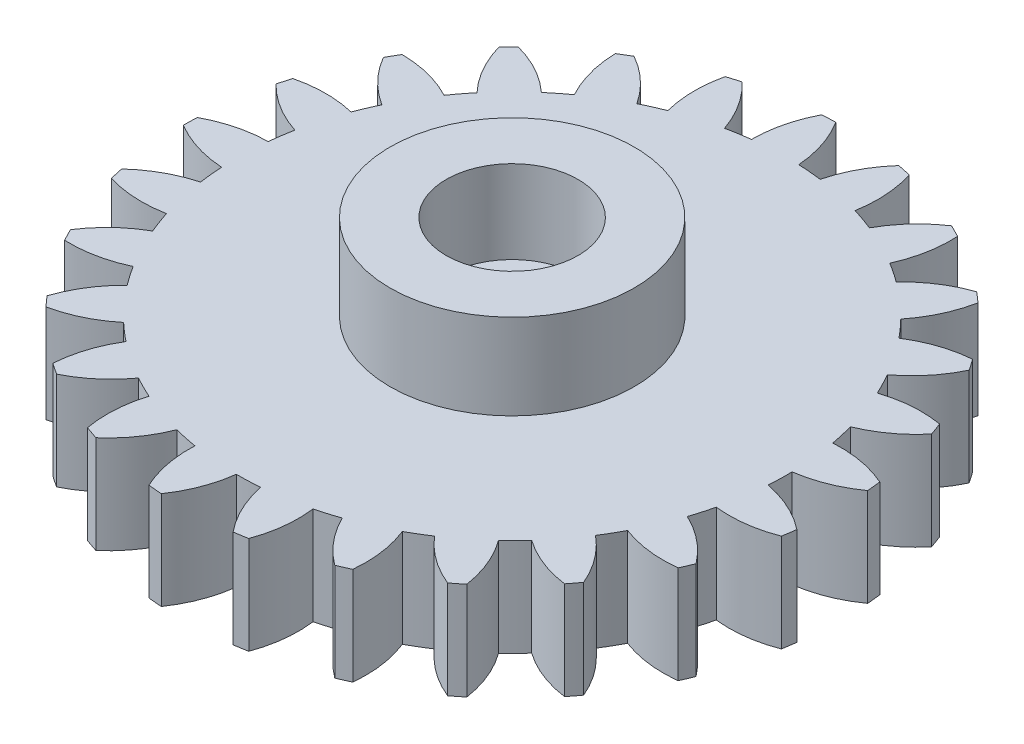
from build123d import *

# Parameters (mm, degrees)
BOSS_EXTRUDE1_DEPTH = 4
SKETCH2_R           = 5
BOSS_EXTRUDE2_DEPTH = 3.5
SKETCH3_R           = 2.7
CUT_EXTRUDE1_DEPTH  = 3.4
SKETCH4_R           = 2.35
CUT_EXTRUDE2_DEPTH  = 1.5


with BuildPart() as part:
    # Sketch1 → Boss-Extrude1 (new body)
    with BuildSketch(Plane(origin=(0, 0, 0), x_dir=(1, 0, 0), z_dir=(0, 1, 0))):
        with BuildLine():
            ThreePointArc((3.901208796, 14.038686533), (3.966253303, 15.234612101), (3.74502345, 16.41169583))
            ThreePointArc((3.74502345, 16.41169583), (3.4723799, 16.473432267), (3.198516489, 16.529510113))
            ThreePointArc((3.198516489, 16.529510113), (2.511969944, 15.548122017), (2.078508173, 14.431618705))
            ThreePointArc((2.078508173, 14.431618705), (1.601109064, 14.483383768), (1.121935684, 14.514727092))
            ThreePointArc((1.121935684, 14.514727092), (0.887522104, 15.689256371), (0.380513774, 16.774342223))
            ThreePointArc((0.380513774, 16.774342223), (0.101082595, 16.766335403), (-0.178122887, 16.752544399))
            ThreePointArc((-0.178122887, 16.752544399), (-0.599039015, 15.631251232), (-0.741219705, 14.442027366))
            ThreePointArc((-0.741219705, 14.442027366), (-1.216493891, 14.373441804), (-1.688407925, 14.284634846))
            ThreePointArc((-1.688407925, 14.284634846), (-2.207550525, 15.363967841), (-2.968480134, 16.288875881))
            ThreePointArc((-2.968480134, 16.288875881), (-3.237141254, 16.211628901), (-3.504145299, 16.128835588))
            ThreePointArc((-3.504145299, 16.128835588), (-3.632983302, 14.938092323), (-3.474949175, 13.750871212))
            ThreePointArc((-3.474949175, 13.750871212), (-3.918235212, 13.566244507), (-4.353237807, 13.362867335))
            ThreePointArc((-4.353237807, 13.362867335), (-5.124489789, 14.279185585), (-6.091528671, 14.985800439))
            ThreePointArc((-6.091528671, 14.985800439), (-6.332538765, 14.844167012), (-6.570564527, 14.697573597))
            ThreePointArc((-6.570564527, 14.697573597), (-6.399229039, 13.512199013), (-5.95090996, 12.401578126))
            ThreePointArc((-5.95090996, 12.401578126), (-6.334354558, 12.112511054), (-6.7051129, 11.807342604))
            ThreePointArc((-6.7051129, 11.807342604), (-7.680013665, 12.503070462), (-8.792399211, 12.946992921))
            ThreePointArc((-8.792399211, 12.946992921), (-8.990614728, 12.749872395), (-9.184706174, 12.548689882))
            ThreePointArc((-9.184706174, 12.548689882), (-8.723962833, 11.443165424), (-8.013528339, 10.478929154))
            ThreePointArc((-8.013528339, 10.478929154), (-8.313038262, 10.103584863), (-8.596256242, 9.71579999))
            ThreePointArc((-8.596256242, 9.71579999), (-9.713549189, 10.147222317), (-10.901386124, 10.3005591))
            ThreePointArc((-10.901386124, 10.3005591), (-11.044352455, 10.060337283), (-11.182314104, 9.817206709))
            ThreePointArc((-11.182314104, 9.817206709), (-10.46111311, 8.860996544), (-9.533202414, 8.103731404))
            ThreePointArc((-9.533202414, 8.103731404), (-9.729958352, 7.665694155), (-9.907840342, 7.21965881))
            ThreePointArc((-9.907840342, 7.21965881), (-11.097321846, 7.359667754), (-12.285974007, 7.212784147))
            ThreePointArc((-12.285974007, 7.212784147), (-12.364708051, 6.944555059), (-12.437871267, 6.674753212))
            ThreePointArc((-12.437871267, 6.674753212), (-11.50152833, 5.927939542), (-10.414445472, 5.425227285))
            ThreePointArc((-10.414445472, 5.425227285), (-10.496084526, 4.952020569), (-10.557453547, 4.475760793))
            ThreePointArc((-10.557453547, 4.475760793), (-11.744384111, 4.315559077), (-12.85916411, 3.877684317))
            ThreePointArc((-12.85916411, 3.877684317), (-12.868718719, 3.598301779), (-12.872486386, 3.318781301))
            ThreePointArc((-12.872486386, 3.318781301), (-11.779835377, 2.828289175), (-10.601885772, 2.611717061))
            ThreePointArc((-10.601885772, 2.611717061), (-10.563278261, 2.133074197), (-10.504278271, 1.656515143))
            ThreePointArc((-10.504278271, 1.656515143), (-11.614078682, 1.206168831), (-12.584940793, 0.504816199))
            ThreePointArc((-12.584940793, 0.504816199), (-12.524715614, 0.231834843), (-12.458850997, -0.039840966))
            ThreePointArc((-12.458850997, -0.039840966), (-11.278547197, -0.243192124), (-10.08374575, -0.160016072))
            ThreePointArc((-10.08374575, -0.160016072), (-9.927317525, -0.614020193), (-9.751655711, -1.060934567))
            ThreePointArc((-9.751655711, -1.060934567), (-10.714593128, -1.773128561), (-11.480534513, -2.693890499))
            ThreePointArc((-11.480534513, -2.693890499), (-11.354313716, -2.943318251), (-11.222955331, -3.190079))
            ThreePointArc((-11.222955331, -3.190079), (-10.029161569, -3.093511889), (-8.89258205, -2.715813928))
            ThreePointArc((-8.89258205, -2.715813928), (-8.628162071, -3.116652557), (-8.34687591, -3.505840978))
            ThreePointArc((-8.34687591, -3.505840978), (-9.102445434, -4.435132885), (-9.61533918, -5.517449271))
            ThreePointArc((-9.61533918, -5.517449271), (-9.431053682, -5.727650955), (-9.242455259, -5.93399176))
            ThreePointArc((-9.242455259, -5.93399176), (-8.110181987, -5.543574046), (-7.103239867, -4.895086329))
            ThreePointArc((-7.103239867, -4.895086329), (-6.747442615, -5.217573301), (-6.378206351, -5.524581628))
            ThreePointArc((-6.378206351, -5.524581628), (-6.87893277, -6.61258062), (-7.106551876, -7.788445534))
            ThreePointArc((-7.106551876, -7.788445534), (-6.875781012, -7.946213407), (-6.641792884, -8.099169115))
            ThreePointArc((-6.641792884, -8.099169115), (-5.642184996, -7.43943218), (-4.828150152, -6.560901574))
            ThreePointArc((-4.828150152, -6.560901574), (-4.403331676, -6.784773846), (-3.969345782, -6.990311618))
            ThreePointArc((-3.969345782, -6.990311618), (-4.183766613, -8.168654718), (-4.111808933, -9.364184243))
            ThreePointArc((-4.111808933, -9.364184243), (-3.849052886, -9.459605167), (-3.584377387, -9.54956501))
            ThreePointArc((-3.584377387, -9.54956501), (-2.780243924, -8.661962551), (-2.210265158, -7.608590366))
            ThreePointArc((-2.210265158, -7.608590366), (-1.743118366, -7.71978122), (-1.271651772, -7.810933742))
            ThreePointArc((-1.271651772, -7.810933742), (-1.186294165, -9.005581318), (-0.819281066, -10.145655938))
            ThreePointArc((-0.819281066, -10.145655938), (-0.541049764, -10.172734267), (-0.26231743, -10.194045736))
            ThreePointArc((-0.26231743, -10.194045736), (0.295814947, -9.134349079), (0.585923772, -7.972322564))
            ThreePointArc((0.585923772, -7.972322564), (1.06604633, -7.96384547), (1.545369644, -7.934885294))
            ThreePointArc((1.545369644, -7.934885294), (1.925142356, -9.070773246), (2.564150092, -10.083757879))
            ThreePointArc((2.564150092, -10.083757879), (2.840374352, -10.040792181), (3.115649745, -9.992116198))
            ThreePointArc((3.115649745, -9.992116198), (3.392711524, -8.826909983), (3.384721804, -7.629243537))
            ThreePointArc((3.384721804, -7.629243537), (3.847652261, -7.501631141), (4.304714649, -7.354377941))
            ThreePointArc((4.304714649, -7.354377941), (4.95503995, -8.360134252), (5.825891117, -9.182379348))
            ThreePointArc((5.825891117, -9.182379348), (6.082752149, -9.072069317), (6.337274035, -8.956464373))
            ThreePointArc((6.337274035, -8.956464373), (6.315856407, -7.758962791), (6.010270165, -6.600910201))
            ThreePointArc((6.010270165, -6.600910201), (6.426920898, -6.362180861), (6.833003449, -6.105887097))
            ThreePointArc((6.833003449, -6.105887097), (7.713019008, -6.918316398), (8.760994824, -7.498157274))
            ThreePointArc((8.760994824, -7.498157274), (8.982353106, -7.327434094), (9.200128938, -7.152164073))
            ThreePointArc((9.200128938, -7.152164073), (8.881577651, -5.997610553), (8.297595995, -4.951936522))
            ThreePointArc((8.297595995, -4.951936522), (8.641787307, -4.617090479), (8.97137436, -4.267860032))
            ThreePointArc((8.97137436, -4.267860032), (10.025785563, -4.835914403), (11.185037854, -5.136917523))
            ThreePointArc((11.185037854, -5.136917523), (11.35698463, -4.91650836), (11.524330752, -4.692586122))
            ThreePointArc((11.524330752, -4.692586122), (10.928661555, -3.653525508), (10.1029782, -2.785933582))
            ThreePointArc((10.1029782, -2.785933582), (10.353083284, -2.376010444), (10.585465673, -1.955786746))
            ThreePointArc((10.585465673, -1.955786746), (11.748019987, -2.243773242), (12.945708667, -2.247025474))
            ThreePointArc((12.945708667, -2.247025474), (13.057439889, -1.990779446), (13.163841329, -1.732274849))
            ThreePointArc((13.163841329, -1.732274849), (12.328482308, -0.873995139), (11.312977976, -0.238999309))
            ThreePointArc((11.312977976, -0.238999309), (11.45328181, 0.220243944), (11.573858095, 0.685056692))
            ThreePointArc((11.573858095, 0.685056692), (12.771507956, 0.695233323), (13.932377842, 0.989936328))
            ThreePointArc((13.932377842, 0.989936328), (13.976873026, 1.265918341), (14.01564419, 1.542762503))
            ThreePointArc((14.01564419, 1.542762503), (12.993084025, 2.166332436), (11.851566587, 2.528833047))
            ThreePointArc((11.851566587, 2.528833047), (11.873253365, 3.008540473), (11.874447295, 3.488736377))
            ThreePointArc((11.874447295, 3.488736377), (13.031939958, 3.796436699), (14.083049324, 4.370577669))
            ThreePointArc((14.083049324, 4.370577669), (14.057512675, 4.648954702), (14.026217428, 4.926743291))
            ThreePointArc((14.026217428, 4.926743291), (12.880707334, 5.276422256), (11.68490253, 5.343650401))
            ThreePointArc((11.68490253, 5.343650401), (11.586609593, 5.813680219), (11.468346148, 6.279086803))
            ThreePointArc((11.468346148, 6.279086803), (12.512952092, 6.864976874), (13.388255872, 7.682480419))
            ThreePointArc((13.388255872, 7.682480419), (13.29429195, 7.945761019), (13.194896688, 8.207039558))
            ThreePointArc((13.194896688, 8.207039558), (11.998413278, 8.260855939), (10.823457921, 8.028587426))
            ThreePointArc((10.823457921, 8.028587426), (10.611361374, 8.459405933), (10.381071482, 8.880779992))
            ThreePointArc((10.381071482, 8.880779992), (11.247154274, 9.708046183), (11.891653912, 10.717545549))
            ThreePointArc((11.891653912, 10.717545549), (11.735166817, 10.949186827), (11.573916909, 11.177538224))
            ThreePointArc((11.573916909, 11.177538224), (10.401639636, 10.932110541), (9.321360492, 10.414939655))
            ThreePointArc((9.321360492, 10.414939655), (9.008787143, 10.77947694), (8.680940764, 11.13034199))
            ThreePointArc((8.680940764, 11.13034199), (9.314081237, 12.147004125), (9.68728045, 13.285068754))
            ThreePointArc((9.68728045, 13.285068754), (9.478102841, 13.470515838), (9.265130213, 13.651591934))
            ThreePointArc((9.265130213, 13.651591934), (8.190717569, 13.12234131), (7.27299255, 12.3527638))
            ThreePointArc((7.27299255, 12.3527638), (6.879582531, 12.628114645), (6.474779459, 12.886424546))
            ThreePointArc((6.474779459, 12.886424546), (6.835195068, 14.028602002), (6.913644378, 15.223723109))
            ThreePointArc((6.913644378, 15.223723109), (6.664919654, 15.351323676), (6.413606158, 15.473746794))
            ThreePointArc((6.413606158, 15.473746794), (5.504567441, 14.693927992), (4.807060586, 13.720299244))
            ThreePointArc((4.807060586, 13.720299244), (4.357533295, 13.889162343), (3.901208796, 14.038686533))
        make_face()
    extrude(amount=BOSS_EXTRUDE1_DEPTH)

    # Sketch2 → Boss-Extrude2 (add)
    with BuildSketch(Plane(origin=(0, 4, 0), x_dir=(1, 0, 0), z_dir=(0, 1, 0))):
        with Locations((0.627447718, 3.276600796)):
            Circle(SKETCH2_R)
    extrude(amount=BOSS_EXTRUDE2_DEPTH)

    # Sketch3 → Cut-Extrude1 (cut)
    with BuildSketch(Plane(origin=(0, 7.5, 0), x_dir=(1, 0, 0), z_dir=(0, 1, 0))):
        with Locations((0.627447718, 3.276600796)):
            Circle(SKETCH3_R)
    extrude(amount=-CUT_EXTRUDE1_DEPTH, mode=Mode.SUBTRACT)

    # Sketch4 → Cut-Extrude2 (cut)
    with BuildSketch(Plane.XZ):
        with Locations((0.627447718, -3.276600796)):
            Circle(SKETCH4_R)
    extrude(amount=-CUT_EXTRUDE2_DEPTH, mode=Mode.SUBTRACT)


solid = part.part
